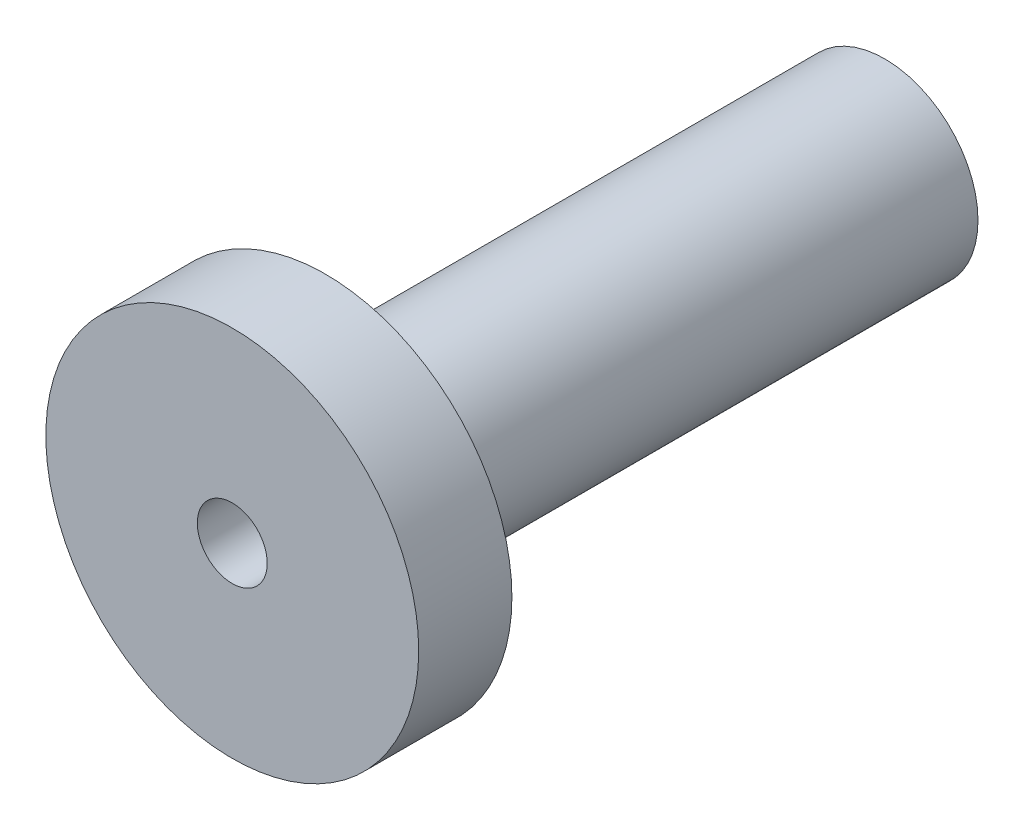
from build123d import *

# Parameters (mm, degrees)
SKETCH2_R          = 0.75
CUT_EXTRUDE1_DEPTH = 15


with BuildPart() as part:
    # Sketch1 → Revolve1 (revolve)
    with BuildSketch(Plane(origin=(0, 0, 0), x_dir=(0, 0, -1), z_dir=(1, 0, 0))):
        Polygon((0, 0), (14, 0), (14, -2), (2, -2), (2, -4), (0, -4), align=None)
    revolve(axis=Axis((0, 0, 0), (0, 0, -1)))

    # Sketch2 → Cut-Extrude1 (cut, through all)
    with BuildSketch(Plane(origin=(0, 0, -14), x_dir=(-1, 0, 0), z_dir=(0, 0, -1))):
        Circle(SKETCH2_R)
    extrude(amount=-CUT_EXTRUDE1_DEPTH, mode=Mode.SUBTRACT)


solid = part.part
